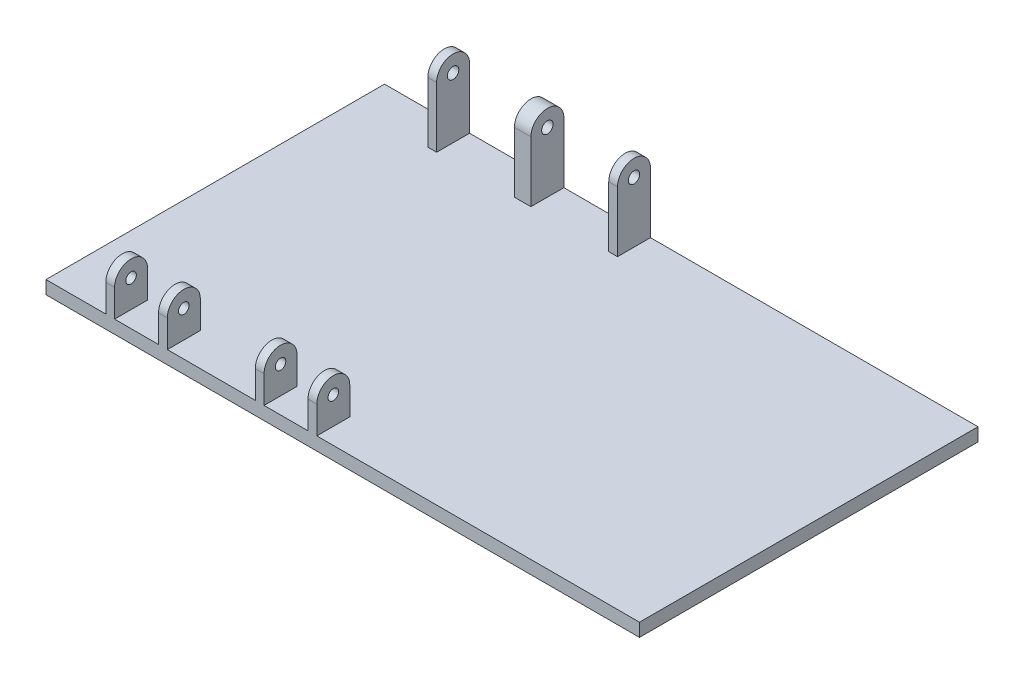
from build123d import *

# Parameters (mm, degrees)
SKETCH1_W               = 342.9
SKETCH1_H               = 195.58
BOSS_EXTRUDE1_DEPTH     = 7.62
SKETCH2_W               = 5.08
SKETCH2_H               = 19.05
BOSS_EXTRUDE2_DEPTH     = 25.4
SKETCH3_R               = 3.048
CUT_EXTRUDE1_DEPTH      = 367.63858527
SKETCH2_4_W             = 5.08
SKETCH2_4_H             = 19.05
SKETCH2_4_W_2           = 9.525
BOSS_EXTRUDE3_DEPTH     = 44.45
CUT_EXTRUDE2_DEPTH      = 361.917448488
CUT_EXTRUDE2_DEPTH_BACK = 492.252
SKETCH4_R               = 3.302


with BuildPart() as part:
    # Sketch1 → Boss-Extrude1 (new body)
    with BuildSketch(Plane(origin=(0, 0, 0), x_dir=(1, 0, 0), z_dir=(0, 1, 0))):
        with Locations((171.45, 97.79)):
            Rectangle(SKETCH1_W, SKETCH1_H)
    extrude(amount=BOSS_EXTRUDE1_DEPTH)

    # Sketch2 → Boss-Extrude2 (add)
    with BuildSketch(Plane(origin=(0, 7.62, 0), x_dir=(1, 0, 0), z_dir=(0, 1, 0))):
        with Locations((37.086314424, 9.525)):
            Rectangle(SKETCH2_W, SKETCH2_H)
        with Locations((153.926314424, 9.525)):
            Rectangle(SKETCH2_W, SKETCH2_H)
        with Locations((123.446314424, 9.525)):
            Rectangle(SKETCH2_W, SKETCH2_H)
        with Locations((67.566314424, 9.525)):
            Rectangle(SKETCH2_W, SKETCH2_H)
    extrude(amount=BOSS_EXTRUDE2_DEPTH)

    # Sketch3 → Cut-Extrude1 (cut, through all)
    with BuildSketch(Plane.ZY.offset(-34.546314424)):
        with Locations((-9.525, 23.495)):
            Circle(SKETCH3_R)
        with BuildLine():
            Line((-19.05, 23.495), (-20.422011891, 33.02))
            Line((-20.422011891, 33.02), (2.969055393, 35.880507904))
            Line((2.969055393, 35.880507904), (0, 23.495))
            ThreePointArc((0, 23.495), (-9.525, 33.02), (-19.05, 23.495))
        make_face()
    extrude(amount=-CUT_EXTRUDE1_DEPTH, mode=Mode.SUBTRACT)

    # Sketch2_4 → Boss-Extrude3 (add)
    with BuildSketch(Plane(origin=(0, 7.62, 0), x_dir=(1, 0, 0), z_dir=(0, 1, 0))):
        with Locations((46.611314424, 186.055)):
            Rectangle(SKETCH2_4_W, SKETCH2_4_H)
        with Locations((151.132314424, 186.055)):
            Rectangle(SKETCH2_4_W, SKETCH2_4_H)
        with Locations((98.871814424, 186.055)):
            Rectangle(SKETCH2_4_W_2, SKETCH2_4_H)
    extrude(amount=BOSS_EXTRUDE3_DEPTH)

    # Sketch4 → Cut-Extrude2 (cut, two sides: drawn at the far end of the back side and taken through both)
    with BuildSketch(Plane.ZY.offset(-44.071314424).offset(-CUT_EXTRUDE2_DEPTH_BACK)):
        with Locations((-186.055, 42.545)):
            Circle(SKETCH4_R)
        with BuildLine():
            Line((-195.58, 42.545), (-197.59428292, 55.074082425))
            Line((-197.59428292, 55.074082425), (-172.116639762, 54.451508438))
            Line((-172.116639762, 54.451508438), (-176.53, 42.545))
            ThreePointArc((-176.53, 42.545), (-186.055, 52.07), (-195.58, 42.545))
        make_face()
    extrude(amount=CUT_EXTRUDE2_DEPTH + CUT_EXTRUDE2_DEPTH_BACK, mode=Mode.SUBTRACT)


solid = part.part
